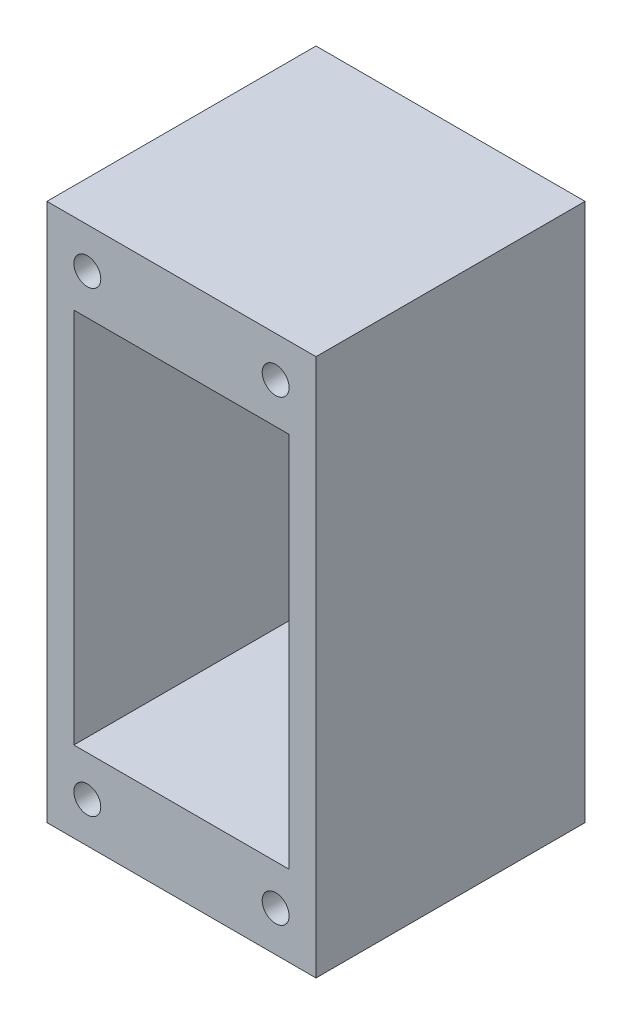
from build123d import *

# Parameters (mm, degrees)
SKETCH1_W           = 50
SKETCH1_H           = 100
SKETCH1_R           = 2.5
BOSS_EXTRUDE1_DEPTH = 50
SKETCH2_W           = 40
SKETCH2_H           = 70
CUT_EXTRUDE1_DEPTH  = 93


with BuildPart() as part:
    # Sketch1 → Boss-Extrude1 (new body)
    with BuildSketch(Plane.XY):
        Rectangle(SKETCH1_W, SKETCH1_H)
        with Locations((-17.5, 42.5)):
            Circle(SKETCH1_R, mode=Mode.SUBTRACT)
        with Locations((17.5, 42.5)):
            Circle(SKETCH1_R, mode=Mode.SUBTRACT)
        with Locations((-17.5, -42.5)):
            Circle(SKETCH1_R, mode=Mode.SUBTRACT)
        with Locations((17.5, -42.5)):
            Circle(SKETCH1_R, mode=Mode.SUBTRACT)
    extrude(amount=BOSS_EXTRUDE1_DEPTH)

    # Sketch2 → Cut-Extrude1 (cut)
    with BuildSketch(Plane.XY.offset(50)):
        Rectangle(SKETCH2_W, SKETCH2_H)
    extrude(amount=-CUT_EXTRUDE1_DEPTH, mode=Mode.SUBTRACT)


solid = part.part
